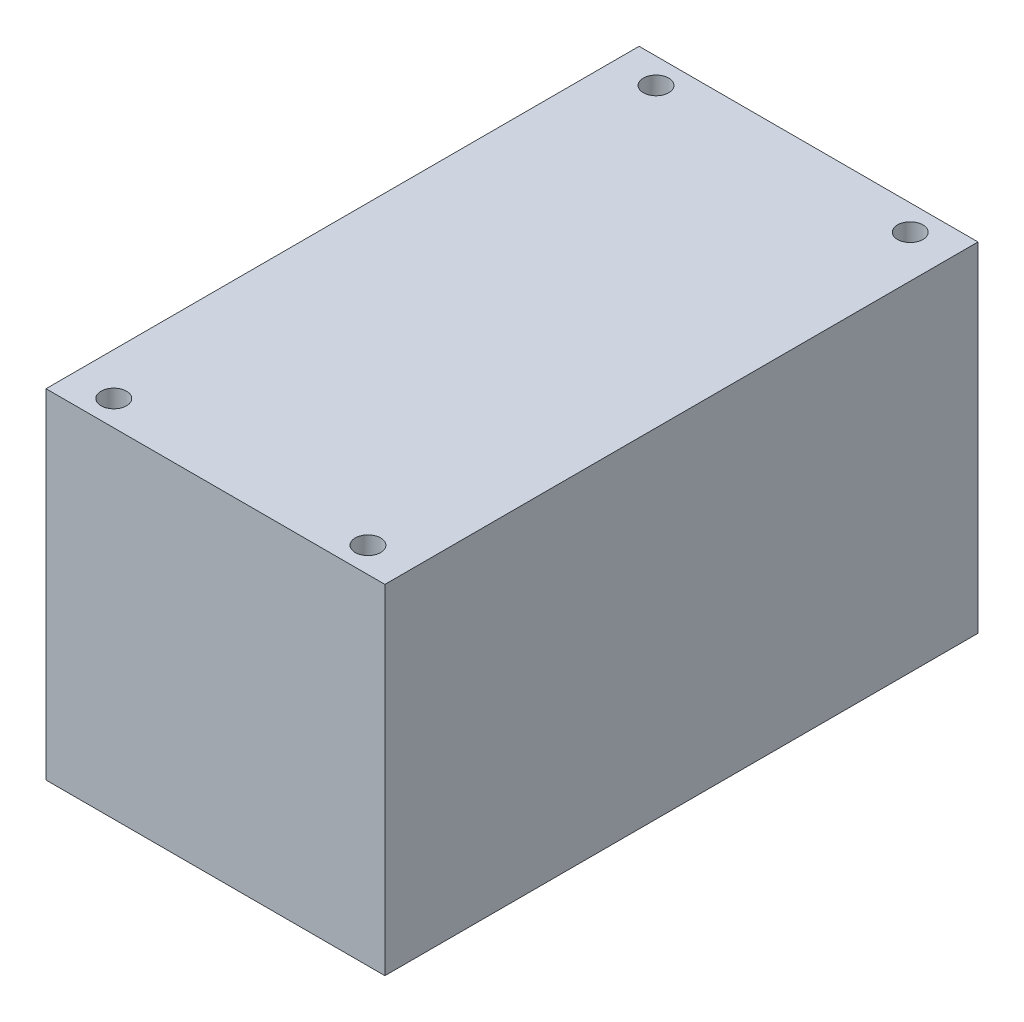
from build123d import *

# Parameters (mm, degrees)
SKETCH_1_W            = 40
SKETCH_1_H            = 40
EXTRUDE_1_DEPTH       = 70
HOLE_WIZARD_3_0_3_1_D = 3


with BuildPart() as part:
    # 草图1 → 凸台-拉伸1 (new body)
    with BuildSketch(Plane.XY):
        Rectangle(SKETCH_1_W, SKETCH_1_H)
    extrude(amount=-EXTRUDE_1_DEPTH)

    # Ø3.0 (3) 直径孔1 (through all)
    with Locations(Plane(origin=(-15, 20, -67), x_dir=(0, 0, 1), z_dir=(0, 1, 0))):
        with Locations((0, 0), (0, 30), (64, 0), (64, 30)):
            Hole(HOLE_WIZARD_3_0_3_1_D / 2)


solid = part.part
